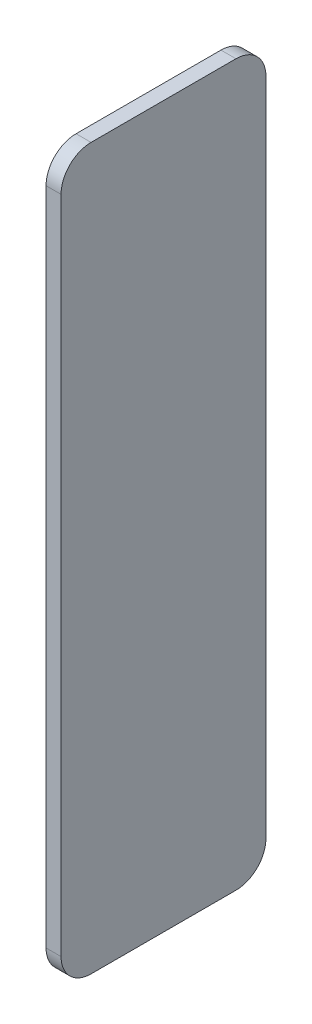
from build123d import *

# Parameters (mm, degrees)
SKETCH1_W           = 68.285556752
SKETCH1_H           = 240
BOSS_EXTRUDE1_DEPTH = 5
FILLET1_R           = 10


with BuildPart() as part:
    # Sketch1 → Boss-Extrude1 (new body)
    with BuildSketch(Plane.ZY.offset(191.482668327)):
        with Locations((-56.88127805, -11.228757924)):
            Rectangle(SKETCH1_W, SKETCH1_H)
    extrude(amount=-BOSS_EXTRUDE1_DEPTH)

    # Fillet1
    fillet1_edges = [part.edges().sort_by_distance(p)[0] for p in [
        (-188.982668327, 108.771242076, -91.024056426),
        (-188.982668327, 108.771242076, -22.738499674),
        (-188.982668327, -131.228757924, -22.738499674),
        (-188.982668327, -131.228757924, -91.024056426),
    ]]
    fillet(fillet1_edges, radius=FILLET1_R)


solid = part.part
